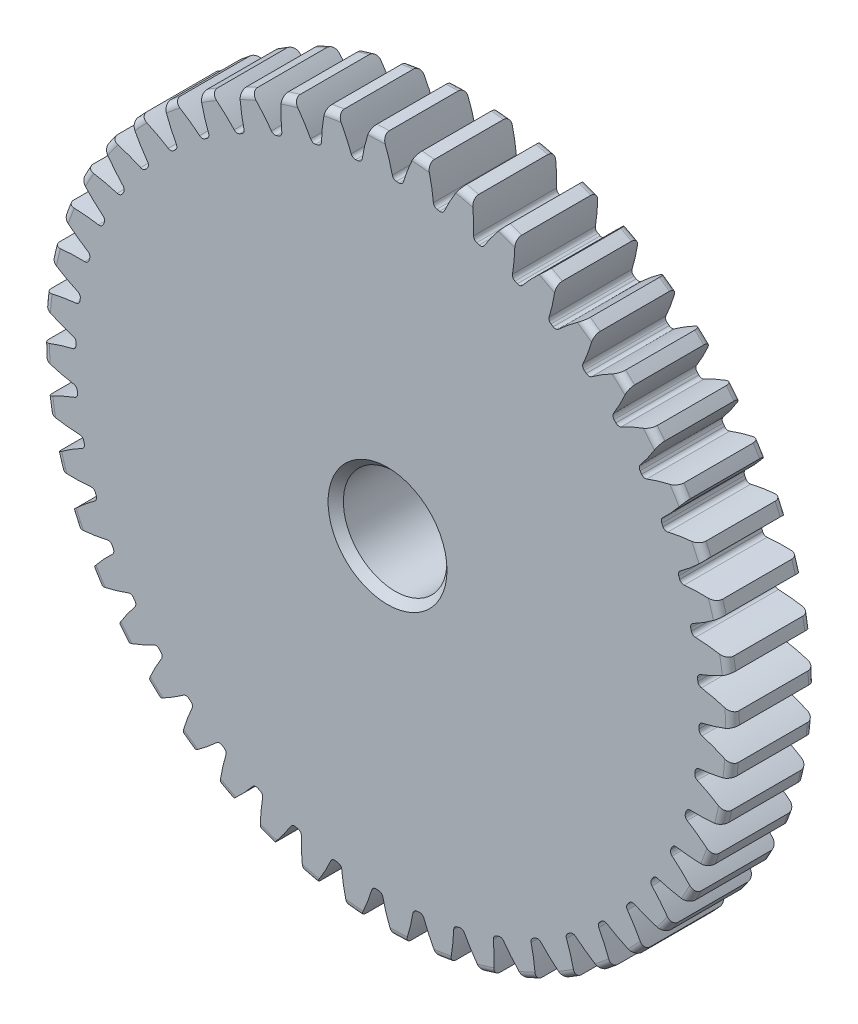
from build123d import *

# Parameters (mm, degrees)
SKETCH1_R                = 26.416
BOSS_EXTRUDE1_DEPTH      = 6.35
SKETCH2_W                = 7.874
SKETCH2_H                = 11.7078125
REVOLVE1_ANGLE           = 360
FILLET2_R                = 0.52832
CUT_EXTRUDE1_DEPTH       = 15.224
FILLET1_R                = 0.332486
CIRPATTERN1_COUNT        = 48
FILLET1_OF_CIRPATTERN1_R = 0.332486
SKETCH5_R                = 3.96875
CUT_EXTRUDE2_DEPTH       = 15.224
CHAMFER1_SIZE            = 0.585390625


with BuildPart() as part:
    # Sketch1 → Boss-Extrude1 (new body)
    with BuildSketch(Plane.XY):
        Circle(SKETCH1_R)
    extrude(amount=-BOSS_EXTRUDE1_DEPTH)

    # Sketch2 → Revolve1 (revolve, symmetric)
    with BuildSketch(Plane(origin=(0, 0, 0), x_dir=(0, 0, -1), z_dir=(1, 0, 0))) as revolve1_sk:
        with Locations((10.287, 5.85390625)):
            Rectangle(SKETCH2_W, SKETCH2_H)
    revolve(axis=Axis((0, 0, -6.35), (0, 0, -1)), revolution_arc=REVOLVE1_ANGLE / 2)
    revolve(revolve1_sk.sketch, axis=Axis((0, 0, -6.35), (0, 0, 1)), revolution_arc=REVOLVE1_ANGLE / 2)

    # Fillet2
    fillet2_edges = [part.edges().sort_by_distance(p)[0] for p in [
        (-26.416, 0, 0),
        (-26.416, 0, -6.35),
        (0, -11.7078125, -6.35),
    ]]
    fillet(fillet2_edges, radius=FILLET2_R)

    # Sketch4 → Cut-Extrude1 (cut, through all)
    with BuildSketch(Plane.XY):
        with BuildLine():
            ThreePointArc((1.140070311, 23.840949145), (0.780947195, 23.855413179), (0.421646998, 23.864467944))
            add(Edge.make_bspline(
                [(-6.71429462, 33.096013011), (-0.802956981, 29.648538809), (0.421646998, 23.864467944)],
                knots=[0, 0, 0, 1, 1, 1], degree=2))
            ThreePointArc((-6.71429462, 33.096013011), (1.104933242, 33.752139962), (8.864506603, 32.586014671))
            add(Edge.make_bspline(
                [(8.864506603, 32.586014671), (2.740349523, 29.532542693), (1.140070311, 23.840949145)],
                knots=[0, 0, 0, 1, 1, 1], degree=2))
        make_face()
    cut_extrude1 = extrude(amount=-CUT_EXTRUDE1_DEPTH, mode=Mode.SUBTRACT)

    # Fillet1
    fillet1_edges = [part.edges().sort_by_distance(p)[0] for p in [
        (1.140070311, 23.840949145, -3.175),
        (0.421646998, 23.864467944, -3.175),
    ]]
    fillet(fillet1_edges, radius=FILLET1_R)

    # CirPattern1: Cut-Extrude1 ×48 about axis
    cirpattern1_axis = Axis((0, 0, -6.35), (0, 0, 1))
    for i in range(1, CIRPATTERN1_COUNT):
        add(cut_extrude1.rotate(cirpattern1_axis, i * 360 / CIRPATTERN1_COUNT), mode=Mode.SUBTRACT)

    # Fillet1 of CirPattern1
    fillet1_of_cirpattern1_edges = [part.edges().sort_by_distance(p)[0] for p in [
        (-1.98155146, 23.785795557, -3.175),
        (-2.696898381, 23.71534009, -3.175),
        (-5.069268335, 23.323660412, -3.175),
        (-5.769299081, 23.160436191, -3.175),
        (-8.070248624, 22.462450971, -3.175),
        (-8.742985473, 22.209250808, -3.175),
        (-10.933144721, 21.216902766, -3.175),
        (-11.567076961, 20.878058987, -3.175),
        (-13.608971681, 19.608327472, -3.175),
        (-14.193252554, 19.189637787, -3.175),
        (-16.051945363, 17.664248258, -3.175),
        (-16.576577662, 17.172876564, -3.175),
        (-18.220265809, 15.41792886, -3.175),
        (-18.676272929, 14.862282662, -3.175),
        (-20.076832455, 12.907804424, -3.175),
        (-20.456411989, 12.297390984, -3.175),
        (-21.589878931, 10.176823875, -3.175),
        (-21.886536168, 9.522087536, -3.175),
        (-22.733516593, 7.271715049, -3.175),
        (-22.942175645, 6.58385853, -3.175),
        (-23.488177484, 4.242185162, -3.175),
        (-23.605268136, 3.532977879, -3.175),
        (-23.840949145, 1.140070311, -3.175),
        (-23.864467944, 0.421646998, -3.175),
        (-23.785795557, -1.98155146, -3.175),
        (-23.71534009, -2.696898381, -3.175),
        (-23.323660412, -5.069268335, -3.175),
        (-23.160436191, -5.769299081, -3.175),
        (-22.462450971, -8.070248624, -3.175),
        (-22.209250808, -8.742985473, -3.175),
        (-21.216902766, -10.933144721, -3.175),
        (-20.878058987, -11.567076961, -3.175),
        (-19.608327472, -13.608971681, -3.175),
        (-19.189637787, -14.193252554, -3.175),
        (-17.664248258, -16.051945363, -3.175),
        (-17.172876564, -16.576577662, -3.175),
        (-15.41792886, -18.220265809, -3.175),
        (-14.862282662, -18.676272929, -3.175),
        (-12.907804424, -20.076832455, -3.175),
        (-12.297390984, -20.456411989, -3.175),
        (-10.176823875, -21.589878931, -3.175),
        (-9.522087536, -21.886536168, -3.175),
        (-7.271715049, -22.733516593, -3.175),
        (-6.58385853, -22.942175645, -3.175),
        (-4.242185162, -23.488177484, -3.175),
        (-3.532977879, -23.605268136, -3.175),
        (-1.140070311, -23.840949145, -3.175),
        (-0.421646998, -23.864467944, -3.175),
        (1.98155146, -23.785795557, -3.175),
        (2.696898381, -23.71534009, -3.175),
        (5.069268335, -23.323660412, -3.175),
        (5.769299081, -23.160436191, -3.175),
        (8.070248624, -22.462450971, -3.175),
        (8.742985473, -22.209250808, -3.175),
        (10.933144721, -21.216902766, -3.175),
        (11.567076961, -20.878058987, -3.175),
        (13.608971681, -19.608327472, -3.175),
        (14.193252554, -19.189637787, -3.175),
        (16.051945363, -17.664248258, -3.175),
        (16.576577662, -17.172876564, -3.175),
        (18.220265809, -15.41792886, -3.175),
        (18.676272929, -14.862282662, -3.175),
        (20.076832455, -12.907804424, -3.175),
        (20.456411989, -12.297390984, -3.175),
        (21.589878931, -10.176823875, -3.175),
        (21.886536168, -9.522087536, -3.175),
        (22.733516593, -7.271715049, -3.175),
        (22.942175645, -6.58385853, -3.175),
        (23.488177484, -4.242185162, -3.175),
        (23.605268136, -3.532977879, -3.175),
        (23.840949145, -1.140070311, -3.175),
        (23.864467944, -0.421646998, -3.175),
        (23.785795557, 1.98155146, -3.175),
        (23.71534009, 2.696898381, -3.175),
        (23.323660412, 5.069268335, -3.175),
        (23.160436191, 5.769299081, -3.175),
        (22.462450971, 8.070248624, -3.175),
        (22.209250808, 8.742985473, -3.175),
        (21.216902766, 10.933144721, -3.175),
        (20.878058987, 11.567076961, -3.175),
        (19.608327472, 13.608971681, -3.175),
        (19.189637787, 14.193252554, -3.175),
        (17.664248258, 16.051945363, -3.175),
        (17.172876564, 16.576577662, -3.175),
        (15.41792886, 18.220265809, -3.175),
        (14.862282662, 18.676272929, -3.175),
        (12.907804424, 20.076832455, -3.175),
        (12.297390984, 20.456411989, -3.175),
        (10.176823875, 21.589878931, -3.175),
        (9.522087536, 21.886536168, -3.175),
        (7.271715049, 22.733516593, -3.175),
        (6.58385853, 22.942175645, -3.175),
        (4.242185162, 23.488177484, -3.175),
        (3.532977879, 23.605268136, -3.175),
    ]]
    fillet(fillet1_of_cirpattern1_edges, radius=FILLET1_OF_CIRPATTERN1_R)

    # Sketch5 → Cut-Extrude2 (cut, through all)
    with BuildSketch(Plane.XY):
        Circle(SKETCH5_R)
    extrude(amount=-CUT_EXTRUDE2_DEPTH, mode=Mode.SUBTRACT)

    # Chamfer1
    chamfer1_edges = [part.edges().sort_by_distance(p)[0] for p in [
        (-3.96875, 0, -14.224),
        (-3.96875, 0, 0),
        (0, -11.7078125, -14.224),
    ]]
    chamfer(chamfer1_edges, length=CHAMFER1_SIZE)


solid = part.part
